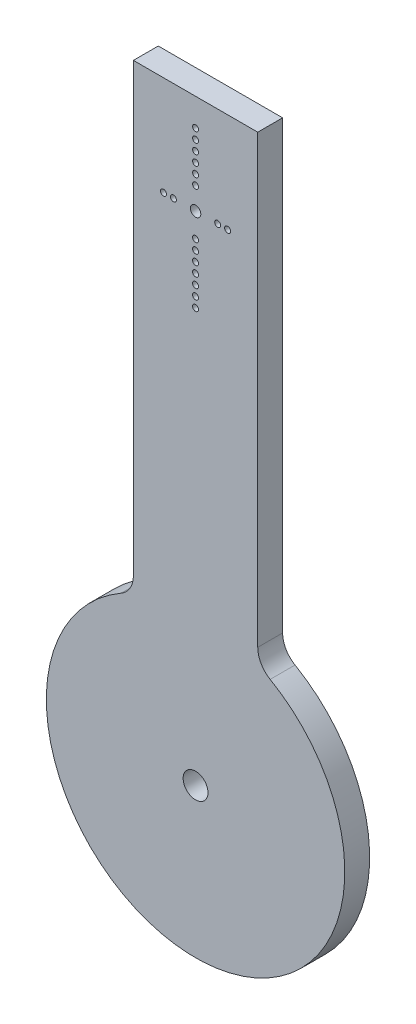
from build123d import *

# Parameters (mm, degrees)
SKETCH1_R           = 1.05
SKETCH1_R_2         = 0.6
SKETCH1_R_3         = 2.5
BOSS_EXTRUDE1_DEPTH = 5


with BuildPart() as part:
    # Sketch1 → Boss-Extrude1 (new body)
    with BuildSketch(Plane.XY):
        with BuildLine():
            Line((-12.5, 120), (12.5, 120))
            Line((12.5, 120), (12.5, 30.310889132))
            ThreePointArc((12.5, 30.310889132), (13.169872981, 27.810889132), (15, 25.980762114))
            ThreePointArc((15, 25.980762114), (0, -30), (-15, 25.980762114))
            ThreePointArc((-15, 25.980762114), (-13.169872981, 27.810889132), (-12.5, 30.310889132))
            Line((-12.5, 30.310889132), (-12.5, 120))
        make_face()
        with Locations((0, 100)):
            Circle(SKETCH1_R, mode=Mode.SUBTRACT)
        with Locations((0, 95.15)):
            Circle(SKETCH1_R_2, mode=Mode.SUBTRACT)
        with Locations((0, 93.15)):
            Circle(SKETCH1_R_2, mode=Mode.SUBTRACT)
        with Locations((0, 91.15)):
            Circle(SKETCH1_R_2, mode=Mode.SUBTRACT)
        with Locations((0, 89.15)):
            Circle(SKETCH1_R_2, mode=Mode.SUBTRACT)
        with Locations((0, 87.15)):
            Circle(SKETCH1_R_2, mode=Mode.SUBTRACT)
        with Locations((0, 85.15)):
            Circle(SKETCH1_R_2, mode=Mode.SUBTRACT)
        with Locations((0, 83.15)):
            Circle(SKETCH1_R_2, mode=Mode.SUBTRACT)
        with Locations((6.45, 100)):
            Circle(SKETCH1_R_2, mode=Mode.SUBTRACT)
        with Locations((4.45, 100)):
            Circle(SKETCH1_R_2, mode=Mode.SUBTRACT)
        with Locations((-4.45, 100)):
            Circle(SKETCH1_R_2, mode=Mode.SUBTRACT)
        with Locations((-6.45, 100)):
            Circle(SKETCH1_R_2, mode=Mode.SUBTRACT)
        with Locations((0, 104.45)):
            Circle(SKETCH1_R_2, mode=Mode.SUBTRACT)
        with Locations((0, 106.45)):
            Circle(SKETCH1_R_2, mode=Mode.SUBTRACT)
        with Locations((0, 108.45)):
            Circle(SKETCH1_R_2, mode=Mode.SUBTRACT)
        with Locations((0, 110.45)):
            Circle(SKETCH1_R_2, mode=Mode.SUBTRACT)
        with Locations((0, 112.45)):
            Circle(SKETCH1_R_2, mode=Mode.SUBTRACT)
        with Locations((0, 114.45)):
            Circle(SKETCH1_R_2, mode=Mode.SUBTRACT)
        Circle(SKETCH1_R_3, mode=Mode.SUBTRACT)
    extrude(amount=BOSS_EXTRUDE1_DEPTH)


solid = part.part
